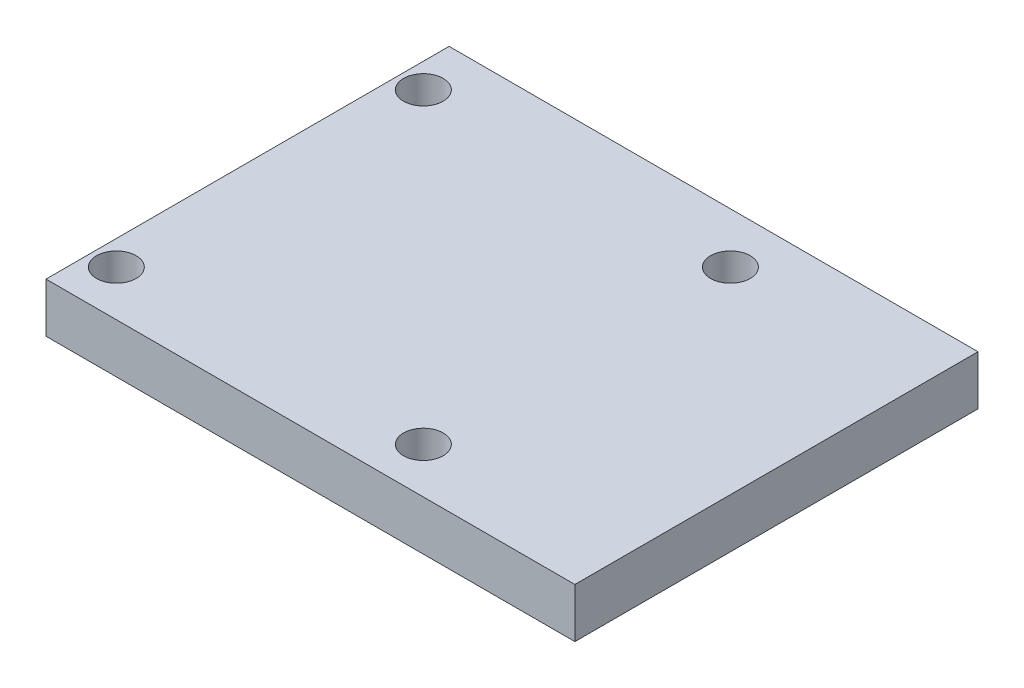
from build123d import *

# Parameters (mm, degrees)
SKETCH1_W           = 53.4
SKETCH1_H           = 40.7
BOSS_EXTRUDE1_DEPTH = 5
SKETCH2_R           = 2
CUT_EXTRUDE1_DEPTH  = 5


with BuildPart() as part:
    # Sketch1 → Boss-Extrude1 (new body)
    with BuildSketch(Plane(origin=(0, 0, 0), x_dir=(1, 0, 0), z_dir=(0, 1, 0))):
        Rectangle(SKETCH1_W, SKETCH1_H)
    extrude(amount=BOSS_EXTRUDE1_DEPTH)

    # Sketch2 → Cut-Extrude1 (cut)
    with BuildSketch(Plane(origin=(0, 5, 0), x_dir=(1, 0, 0), z_dir=(0, 1, 0))):
        with Locations((-24.2, 15.25)):
            Circle(SKETCH2_R)
        with Locations((-24.2, -15.75)):
            Circle(SKETCH2_R)
        with Locations((6.8, 15.25)):
            Circle(SKETCH2_R)
        with Locations((6.8, -15.75)):
            Circle(SKETCH2_R)
    extrude(amount=-CUT_EXTRUDE1_DEPTH, mode=Mode.SUBTRACT)


solid = part.part
